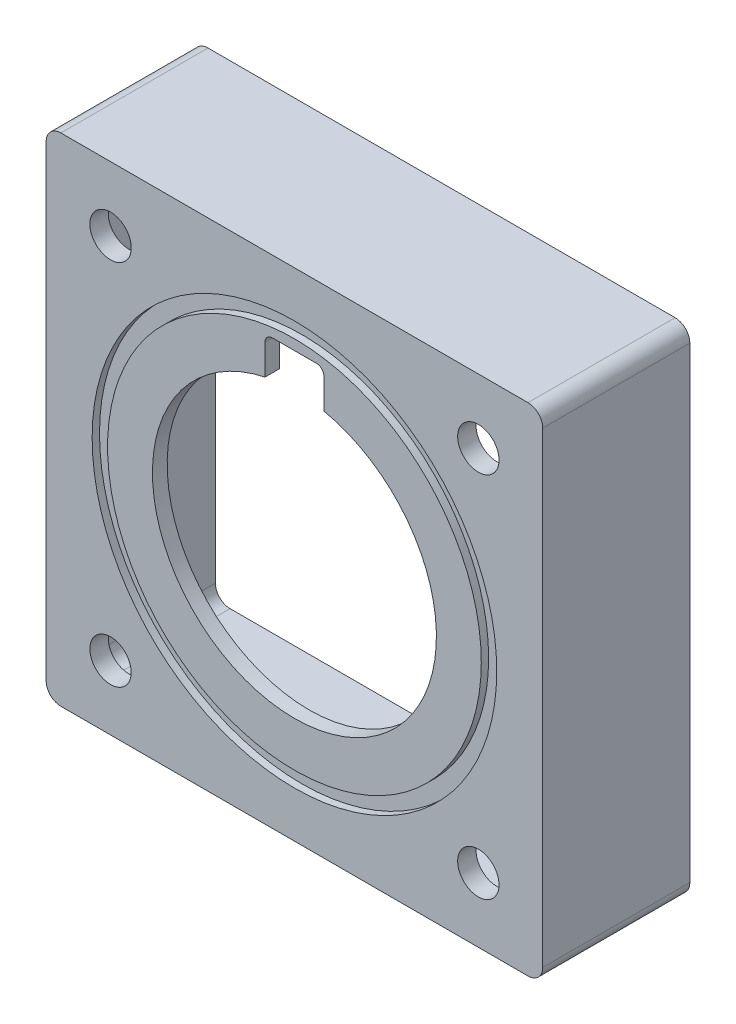
from build123d import *

# Parameters (mm, degrees)
SKETCH1_W               = 85.725
SKETCH1_H               = 85.725
SKETCH1_R               = 24.511
BOSS_EXTRUDE1_DEPTH     = 25.4
SKETCH2_R               = 3.572453457
CUT_EXTRUDE1_DEPTH      = 26.4
MIRROR2_COPY_1_SKETCH_R = 3.572453457
MIRROR2_COPY_1_DEPTH    = 26.4
SKETCH3_W               = 78.105
SKETCH3_H               = 78.105
CUT_EXTRUDE2_DEPTH      = 22.225
FILLET1_R               = 2.54
SKETCH5_R               = 34.925
SKETCH5_R_2             = 32.258
CUT_EXTRUDE4_DEPTH      = 1.27
SKETCH6_W               = 10.16
SKETCH6_H               = 11.43
CUT_EXTRUDE5_DEPTH      = 26.4
FILLET2_R               = 1.27
SKETCH7_R               = 28.6131
CUT_EXTRUDE6_DEPTH      = 0.635


with BuildPart() as part:
    # Sketch1 → Boss-Extrude1 (new body)
    with BuildSketch(Plane.XY):
        Rectangle(SKETCH1_W, SKETCH1_H)
        Circle(SKETCH1_R, mode=Mode.SUBTRACT)
    extrude(amount=BOSS_EXTRUDE1_DEPTH)

    # Sketch2 → Cut-Extrude1 (cut, through all)
    with BuildSketch(Plane.XY.offset(25.4)):
        with Locations((-31.75, 31.75)):
            Circle(SKETCH2_R)
    cut_extrude1 = extrude(amount=-CUT_EXTRUDE1_DEPTH, mode=Mode.SUBTRACT)

    # Mirror1: Cut-Extrude1 across plane
    add(cut_extrude1.mirror(Plane(origin=(0, 0, 0), x_dir=(0, 0, 1), z_dir=(1, 0, 0))), mode=Mode.SUBTRACT)

    # Mirror2: Cut-Extrude1 across plane
    add(cut_extrude1.mirror(Plane.ZX), mode=Mode.SUBTRACT)

    # Mirror2 copy 1 sketch → Mirror2 copy 1 (cut, through all)
    with BuildSketch(Plane(origin=(0, 0, 25.4), x_dir=(-1, 0, 0), z_dir=(0, 0, 1))):
        with Locations((-31.75, 31.75)):
            Circle(MIRROR2_COPY_1_SKETCH_R)
    extrude(amount=-MIRROR2_COPY_1_DEPTH, mode=Mode.SUBTRACT)

    # Sketch3 → Cut-Extrude2 (cut)
    with BuildSketch(Plane(origin=(0, 0, 0), x_dir=(-1, 0, 0), z_dir=(0, 0, -1))):
        Rectangle(SKETCH3_W, SKETCH3_H)
    extrude(amount=-CUT_EXTRUDE2_DEPTH, mode=Mode.SUBTRACT)

    # Fillet1
    fillet1_edges = [part.edges().sort_by_distance(p)[0] for p in [
        (-39.0525, -39.0525, 11.1125),
        (-39.0525, 39.0525, 11.1125),
        (39.0525, 39.0525, 11.1125),
        (39.0525, -39.0525, 11.1125),
        (-42.8625, 42.8625, 12.7),
        (42.8625, 42.8625, 12.7),
        (42.8625, -42.8625, 12.7),
        (-42.8625, -42.8625, 12.7),
    ]]
    fillet(fillet1_edges, radius=FILLET1_R)

    # Sketch5 → Cut-Extrude4 (cut)
    with BuildSketch(Plane.XY.offset(25.4)):
        Circle(SKETCH5_R)
        Circle(SKETCH5_R_2, mode=Mode.SUBTRACT)
    extrude(amount=-CUT_EXTRUDE4_DEPTH, mode=Mode.SUBTRACT)

    # Sketch6 → Cut-Extrude5 (cut, through all)
    with BuildSketch(Plane.XY.offset(25.4)):
        with Locations((0, 24.765)):
            Rectangle(SKETCH6_W, SKETCH6_H)
    extrude(amount=-CUT_EXTRUDE5_DEPTH, mode=Mode.SUBTRACT)

    # Fillet2
    fillet2_edges = [part.edges().sort_by_distance(p)[0] for p in [
        (-5.08, 30.48, 23.8125),
        (5.08, 30.48, 23.8125),
    ]]
    fillet(fillet2_edges, radius=FILLET2_R)

    # Sketch7 → Cut-Extrude6 (cut)
    with BuildSketch(Plane(origin=(0, 0, 22.225), x_dir=(-1, 0, 0), z_dir=(0, 0, -1))):
        Circle(SKETCH7_R)
    extrude(amount=-CUT_EXTRUDE6_DEPTH, mode=Mode.SUBTRACT)


solid = part.part
